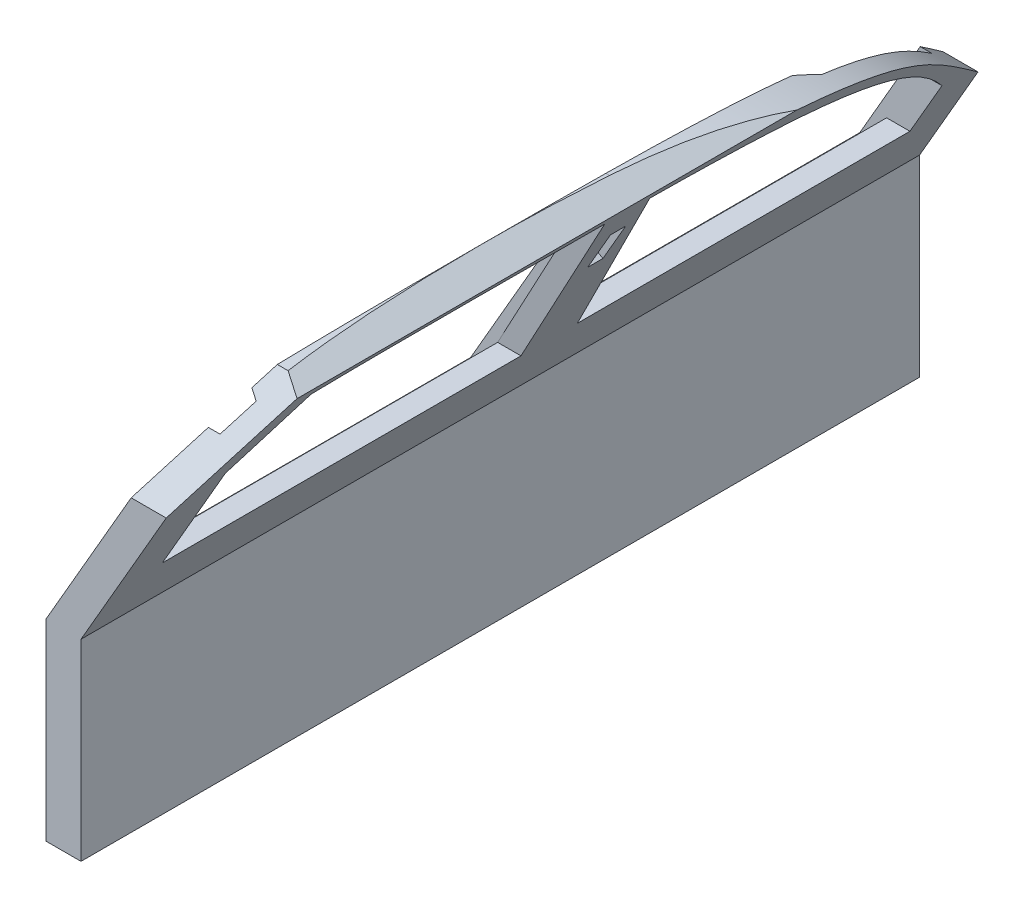
from build123d import *

# Parameters (mm, degrees)
EXTRUDE_1_DEPTH          = 300
CUT_EXTRUDE_1_DEPTH      = 1.0000001
CUT_EXTRUDE_1_DEPTH_BACK = 831.0000001
SKETCH_4_W               = 15
SKETCH_4_H               = 45
CUT_EXTRUDE_2_DEPTH      = 243.720162759
SKETCH_4_3_W             = 15
SKETCH_4_3_H             = 45
CUT_EXTRUDE_3_DEPTH      = 10


with BuildPart() as part:
    # 스케치1 → 보스-돌출1 (new body)
    with BuildSketch(Plane(origin=(0, 0, 0), x_dir=(0, 0, -1), z_dir=(1, 0, 0))):
        with BuildLine():
            Line((-41.993007726, 32.892860384), (-41.993007726, -303.619075042))
            Line((-41.993007726, -303.619075042), (788.006992274, -303.619075042))
            Line((788.006992274, -303.619075042), (788.006992274, -12.90547458))
            add(Edge.make_bspline(
                [(788.006992274, -12.90547458), (680.261509472, 78.254339674), (631.210016853, 128.415858034), (368.750142796, 135.255878696)],
                knots=[0, 0, 0, 0, 1, 1, 1, 1], degree=3))
            add(Edge.make_bspline(
                [(45.325655749, 132.198658827), (134.989620851, 137.211386353), (265.463569923, 138.011524869), (368.750142796, 135.255878696)],
                knots=[0, 0, 0, 0, 1, 1, 1, 1], degree=3))
            Line((45.325655749, 132.198658827), (-41.993007726, 32.892860384))
        make_face()
        with BuildLine():
            Line((4.116595834, 54.214584045), (54.427658026, 114.389853292))
            add(Edge.make_bspline(
                [(54.427658026, 114.389853292), (122.914694658, 118.068796405), (254.727094278, 116.434615788), (344.321994749, 115.599177573)],
                knots=[0, 0, 0, 0, 0.843637698, 0.843637698, 0.843637698, 0.843637698], degree=3))
            Line((344.321994749, 115.599177573), (359.116595834, -53.619075042))
            Line((359.116595834, -53.619075042), (4.116595834, -53.619075042))
            Line((4.116595834, -53.619075042), (4.116595834, 54.214584045))
        make_face(mode=Mode.SUBTRACT)
        with BuildLine():
            Line((414.932922958, -53.619075042), (389.116595834, 115.255878696))
            add(Edge.make_bspline(
                [(389.116595834, 115.255878696), (584.597474826, 110.825479528), (668.447748965, 84.913988672), (744.116595834, 1.380924958)],
                knots=[0.027735734, 0.027735734, 0.027735734, 0.027735734, 0.842070206, 0.842070206, 0.842070206, 0.842070206], degree=3))
            Line((744.116595834, 1.380924958), (744.116595834, -53.619075042))
            Line((744.116595834, -53.619075042), (414.932922958, -53.619075042))
        make_face(mode=Mode.SUBTRACT)
    extrude(amount=EXTRUDE_1_DEPTH)

    # 스케치2 → 컷-돌출1 (cut, two sides)
    with BuildSketch(Plane.XY.offset(41.993007726)) as cut_extrude_1_sk:
        Polygon((179.652203691, 32.892860384), (239.655287588, 136.821250303), (265.636049701, 121.821250303), (214.293219842, 32.892860384), (300, 32.892860384), (300, -303.619075042), (341.364714008, -303.619075042), (341.364714008, 251.457374482), (0, 251.457374482), (0, 32.892860384), align=None)
        Polygon((95.31772029, -113.178749697), (179.652203691, 32.892860384), (0, 32.892860384), (0, -303.619075042), (95.31772029, -303.619075042), align=None)
        Polygon((300, 32.892860384), (214.293219842, 32.892860384), (129.958736441, -113.178749697), (129.958736441, -303.619075042), (300, -303.619075042), align=None)
    extrude(amount=CUT_EXTRUDE_1_DEPTH, mode=Mode.SUBTRACT)
    extrude(cut_extrude_1_sk.sketch, amount=-CUT_EXTRUDE_1_DEPTH_BACK, mode=Mode.SUBTRACT)

    # 스케치4 → 컷-돌출2 (cut, through all)
    with BuildSketch(Plane(origin=(120.496126421, -69.568471025, 0), x_dir=(0, 0, 1), z_dir=(-0.866025404, 0.5, 0))):
        with Locations((-374.116595834, 175.489898801)):
            Rectangle(SKETCH_4_W, SKETCH_4_H)
    extrude(amount=-CUT_EXTRUDE_2_DEPTH, mode=Mode.SUBTRACT)

    # 스케치4<3> → 컷-돌출3 (cut)
    with BuildSketch(Plane(origin=(120.496126421, -69.568471025, 0), x_dir=(0, 0, 1), z_dir=(-0.866025404, 0.5, 0))):
        Polygon((-744.116595834, 18.416776129), (-744.116595834, 213.416776129), (-389.116595834, 213.416776129), (-389.116595834, 17.989898801), (-389.116595834, -11.583223871), (-744.116595834, -11.583223871), align=None)
        Polygon((-359.116595834, 18.416776129), (-359.116595834, 212.989898801), (-4.116595834, 212.989898801), (-4.116595834, 17.989898801), (-4.116595834, -12.010101199), (-359.116595834, -12.010101199), align=None)
        with Locations((-374.116595834, 175.489898801)):
            Rectangle(SKETCH_4_3_W, SKETCH_4_3_H)
    extrude(amount=-CUT_EXTRUDE_3_DEPTH, mode=Mode.SUBTRACT)


solid = part.part
